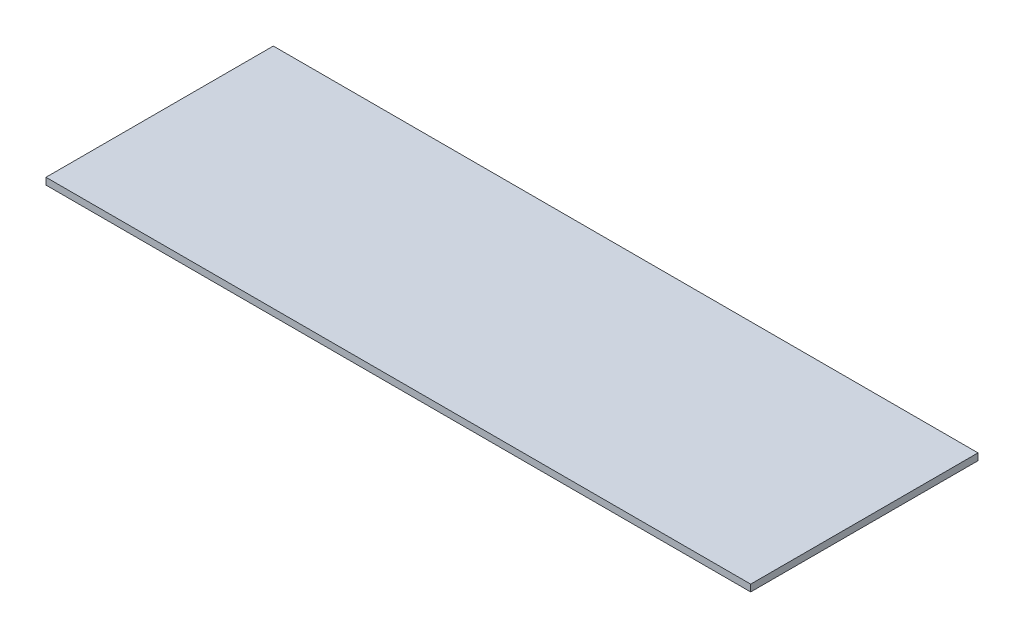
from build123d import *

# Parameters (mm, degrees)
SKETCH1_W           = 310
SKETCH1_H           = 100
BOSS_EXTRUDE1_DEPTH = 3


with BuildPart() as part:
    # Sketch1 → Boss-Extrude1 (new body)
    with BuildSketch(Plane(origin=(0, 0, 0), x_dir=(1, 0, 0), z_dir=(0, 1, 0))):
        Rectangle(SKETCH1_W, SKETCH1_H)
    extrude(amount=BOSS_EXTRUDE1_DEPTH)


solid = part.part
